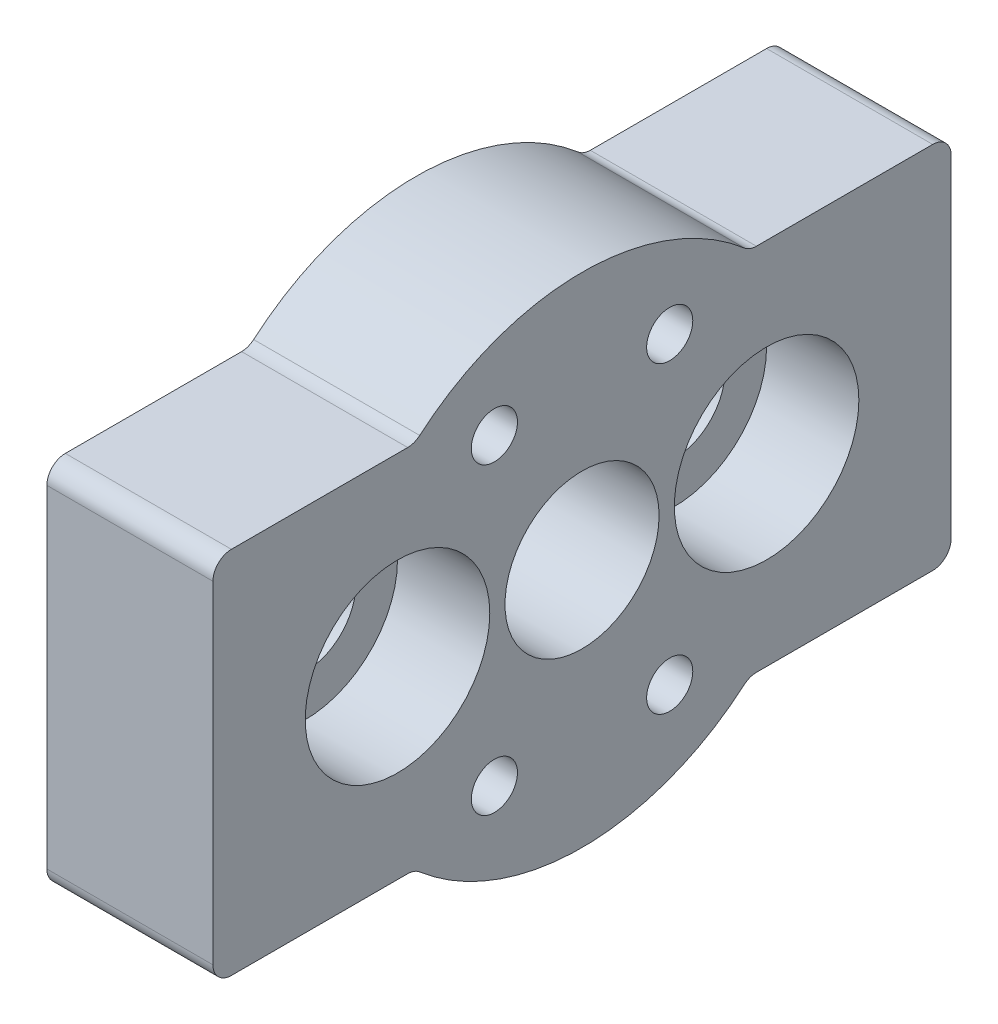
from build123d import *

# Parameters (mm, degrees)
ROTARY_PLATE_SKETCH_W          = 40
ROTARY_PLATE_SKETCH_H          = 20
ROTARY_PLATE_SKETCH_R          = 4.175
Y_PLATE_BOSS_EXTRUDE_DEPTH     = 9
CBORE_FOR_M5_SHCS1_D           = 5.5
CBORE_FOR_M5_SHCS1_CBORE_D     = 10
CBORE_FOR_M5_SHCS1_CBORE_DEPTH = 5
FILLET1_R                      = 1
TAP_DRILL_FOR_M3X0_5_TAP1_D    = 2.5
CIRPATTERN1_COUNT              = 6


with BuildPart() as part:
    # Rotary Plate Sketch → Y Plate Boss-Extrude (new body)
    with BuildSketch(Plane(origin=(0, 0, 0), x_dir=(0, 0, -1), z_dir=(1, 0, 0))):
        with BuildLine():
            ThreePointArc((9.069178574, 10), (0, 13.5), (-9.069178574, 10))
            Line((-9.069178574, 10), (9.069178574, 10))
        make_face()
        Rectangle(ROTARY_PLATE_SKETCH_W, ROTARY_PLATE_SKETCH_H)
        Circle(ROTARY_PLATE_SKETCH_R, mode=Mode.SUBTRACT)
        with BuildLine():
            Line((9.069178574, -10), (-9.069178574, -10))
            ThreePointArc((-9.069178574, -10), (0, -13.5), (9.069178574, -10))
        make_face()
    extrude(amount=-Y_PLATE_BOSS_EXTRUDE_DEPTH)

    # CBORE for M5 SHCS1 (through all)
    with Locations(Plane(origin=(0, 0, 0), x_dir=(0, 0, -1), z_dir=(1, 0, 0))):
        with Locations((-10, 0), (10, 0)):
            CounterBoreHole(CBORE_FOR_M5_SHCS1_D / 2, CBORE_FOR_M5_SHCS1_CBORE_D / 2, CBORE_FOR_M5_SHCS1_CBORE_DEPTH)

    # Fillet1
    fillet1_edges = [part.edges().sort_by_distance(p)[0] for p in [
        (-4.5, 10, -9.069178574),
        (-4.5, 10, -20),
        (-4.5, -10, -20),
        (-4.5, -10, -9.069178574),
        (-4.5, -10, 9.069178574),
        (-4.5, -10, 20),
        (-4.5, 10, 20),
        (-4.5, 10, 9.069178574),
    ]]
    fillet(fillet1_edges, radius=FILLET1_R)

    # Tap Drill for M3x0.5 Tap1 (through all)
    with Locations(Plane(origin=(0, 0, 0), x_dir=(0, 0, -1), z_dir=(1, 0, 0))):
        with Locations((4.75, 8.227241336)):
            tap_drill_for_m3x0_5_tap1 = Hole(TAP_DRILL_FOR_M3X0_5_TAP1_D / 2)

    # CirPattern1: Tap Drill for M3x0.5 Tap1 ×6 about axis, 2 skipped
    cirpattern1_axis = Axis((-9, 0, 0), (-1, 0, 0))
    add([tap_drill_for_m3x0_5_tap1.rotate(cirpattern1_axis, i * 360 / CIRPATTERN1_COUNT) for i in range(1, CIRPATTERN1_COUNT) if i not in (1, 4)], mode=Mode.SUBTRACT)


solid = part.part
